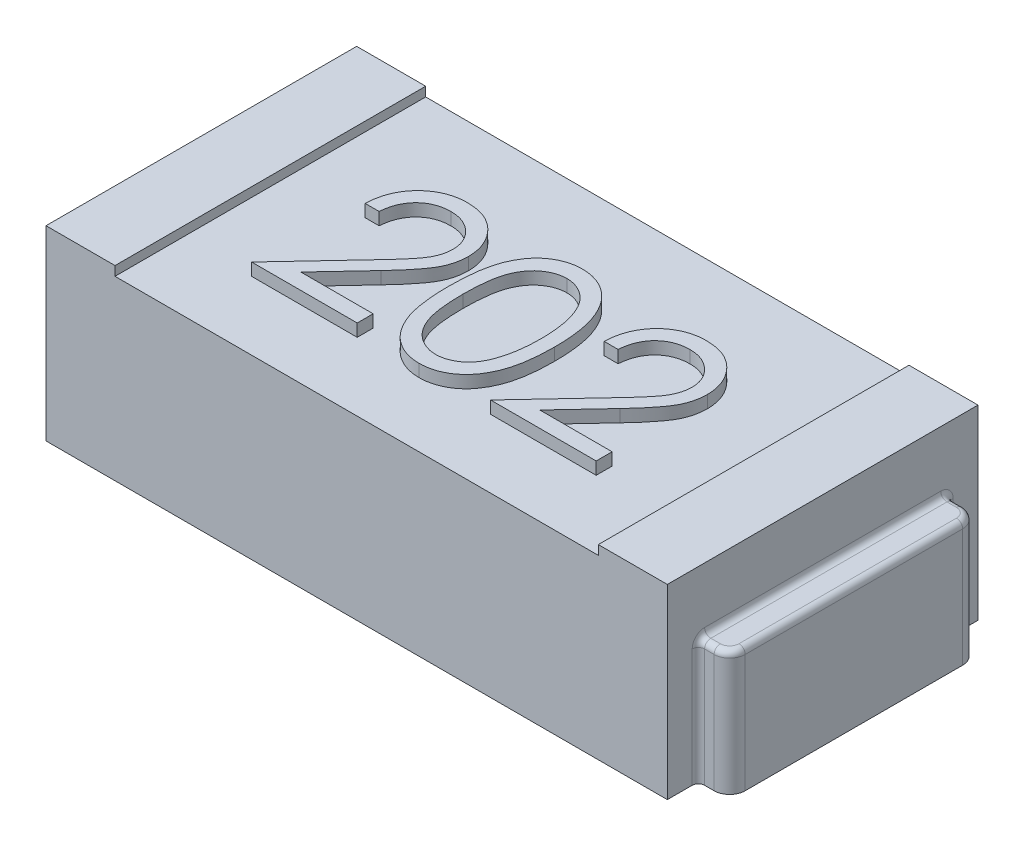
from build123d import *

# Parameters (mm, degrees)
ESQUISSE1_W             = 2
ESQUISSE1_H             = 1
BOSS_EXTRU_1_DEPTH      = 0.6
ESQUISSE2_W             = 1.555645222
ESQUISSE2_H             = 1
ENL_V_MAT_EXTRU_1_DEPTH = 0.03
BOSS_EXTRU_2_DEPTH      = 0.4
CONG_1_R                = 0.02
CONG_1_OF_SYM_TRIE2_R   = 0.02
BOSS_EXTRU_3_DEPTH      = 0.04


with BuildPart() as part:
    # Esquisse1 → Boss.-Extru.1 (new body)
    with BuildSketch(Plane(origin=(0, 0, 0), x_dir=(1, 0, 0), z_dir=(0, 1, 0))):
        Rectangle(ESQUISSE1_W, ESQUISSE1_H)
    extrude(amount=BOSS_EXTRU_1_DEPTH)

    # Esquisse2 → Enlèv. mat.-Extru.1 (cut)
    with BuildSketch(Plane(origin=(0, 0.6, 0), x_dir=(1, 0, 0), z_dir=(0, 1, 0))):
        Rectangle(ESQUISSE2_W, ESQUISSE2_H)
    extrude(amount=-ENL_V_MAT_EXTRU_1_DEPTH, mode=Mode.SUBTRACT)

    # Esquisse3 → Boss.-Extru.2 (add)
    with BuildSketch(Plane(origin=(0, 0, 0), x_dir=(1, 0, 0), z_dir=(0, 1, 0))):
        with BuildLine():
            Line((1, 0.4), (1.050552667, 0.4))
            ThreePointArc((1.050552667, 0.4), (1.085908006, 0.385355339), (1.100552667, 0.35))
            Line((1.100552667, 0.35), (1.100552667, -0.35))
            ThreePointArc((1.100552667, -0.35), (1.085908006, -0.385355339), (1.050552667, -0.4))
            Line((1.050552667, -0.4), (1, -0.4))
            Line((1, -0.4), (1, 0.4))
        make_face()
    boss_extru_2 = extrude(amount=BOSS_EXTRU_2_DEPTH)

    # Congé1
    cong_1_edges = [part.edges().sort_by_distance(p)[0] for p in [
        (1, 0.2, -0.4),
        (1, 0.2, 0.4),
        (1, 0.4, 0),
        (1.025276334, 0.4, 0.4),
        (1.085908006, 0.4, 0.385355339),
        (1.100552667, 0.4, 0),
        (1.085908006, 0.4, -0.385355339),
        (1.025276334, 0.4, -0.4),
    ]]
    fillet(cong_1_edges, radius=CONG_1_R)

    # Symétrie2: Boss.-Extru.2 across plane
    add(boss_extru_2.mirror(Plane(origin=(0, 0, 0), x_dir=(0, 0, 1), z_dir=(1, 0, 0))))

    # Congé1 of Symétrie2
    cong_1_of_sym_trie2_edges = [part.edges().sort_by_distance(p)[0] for p in [
        (-1, 0.2, -0.4),
        (-1, 0.2, 0.4),
        (-1, 0.4, 0),
        (-1.025276334, 0.4, 0.4),
        (-1.085908006, 0.4, 0.385355339),
        (-1.100552667, 0.4, 0),
        (-1.085908006, 0.4, -0.385355339),
        (-1.025276334, 0.4, -0.4),
    ]]
    fillet(cong_1_of_sym_trie2_edges, radius=CONG_1_OF_SYM_TRIE2_R)

    # Esquisse4 → Boss.-Extru.3 (add)
    with BuildSketch(Plane(origin=(0, 0.57, 0), x_dir=(1, 0, 0), z_dir=(0, 1, 0))):
        with BuildLine():
            Line((0.275641026, 0.065854324), (0.230769231, 0.065854324))
            add(Edge.make_bspline(
                [(0.230769231, 0.065854324), (0.231061681, 0.071807307), (0.231636046, 0.08349881), (0.234325802, 0.100545082), (0.238174498, 0.116838625), (0.243616135, 0.132248612), (0.250374174, 0.146911299), (0.258478464, 0.160768444), (0.268077586, 0.173767185), (0.278964262, 0.18578702), (0.290788353, 0.196813816), (0.303546344, 0.206335994), (0.316952777, 0.214381375), (0.330966977, 0.221107267), (0.345747057, 0.226155816), (0.361158894, 0.229901765), (0.377270199, 0.232155528), (0.388247345, 0.232397784), (0.393830128, 0.23252099)],
                knots=[0, 0, 0, 0, 1.7869e-05, 3.5094e-05, 5.1686e-05, 6.8032e-05, 8.4031e-05, 0.000100058, 0.000116104, 0.000132416, 0.000148647, 0.000164532, 0.000180078, 0.00019549, 0.000211074, 0.000226841, 0.000243017, 0.000259759, 0.000259759, 0.000259759, 0.000259759], degree=3))
            add(Edge.make_bspline(
                [(0.393830128, 0.23252099), (0.39931271, 0.232392639), (0.410085788, 0.232140434), (0.425808933, 0.229974573), (0.440777118, 0.226582346), (0.454961085, 0.221823), (0.468247665, 0.215425225), (0.480736672, 0.207739862), (0.492576787, 0.198851315), (0.503234899, 0.188386485), (0.513021768, 0.177214715), (0.521464947, 0.165287872), (0.528695399, 0.152969403), (0.53472221, 0.140165374), (0.539158802, 0.126755227), (0.542527117, 0.112934198), (0.544431033, 0.098559225), (0.544723237, 0.088829717), (0.544871795, 0.08388317)],
                knots=[0, 0, 0, 0, 1.6441e-05, 3.2306e-05, 4.7516e-05, 6.2435e-05, 7.7085e-05, 9.1652e-05, 0.000106376, 0.000121393, 0.000136374, 0.000150882, 0.000165157, 0.000179183, 0.000193247, 0.000207458, 0.000221808, 0.000236648, 0.000236648, 0.000236648, 0.000236648], degree=3))
            add(Edge.make_bspline(
                [(0.544871795, 0.08388317), (0.5446299, 0.076919193), (0.544150356, 0.063113449), (0.540048302, 0.042825611), (0.533641657, 0.023169408), (0.525927749, 0.007349794), (0.518145972, -0.005397848), (0.511133471, -0.015893378), (0.502924212, -0.027194159), (0.493398712, -0.03926235), (0.482754016, -0.052192479), (0.470893707, -0.065976736), (0.45773321, -0.080472703), (0.448496281, -0.090373503), (0.443709936, -0.09550385)],
                knots=[0, 0, 0, 0, 2.0874e-05, 4.1382e-05, 6.1843e-05, 8.2763e-05, 9.3997e-05, 0.000106637, 0.000120621, 0.000135888, 0.000152753, 0.000170863, 0.000190435, 0.000211484, 0.000211484, 0.000211484, 0.000211484], degree=3))
            Line((0.443709936, -0.09550385), (0.318609776, -0.229017471))
            Line((0.318609776, -0.229017471), (0.551282051, -0.229017471))
            Line((0.551282051, -0.229017471), (0.551282051, -0.280299523))
            Line((0.551282051, -0.280299523), (0.211538462, -0.280299523))
            Line((0.211538462, -0.280299523), (0.405448718, -0.073368433))
            add(Edge.make_bspline(
                [(0.405448718, -0.073368433), (0.410169845, -0.068440103), (0.419238163, -0.058973791), (0.432064245, -0.045153368), (0.443584101, -0.032332005), (0.4538723, -0.020533927), (0.462705658, -0.00958656), (0.470544548, 0.000155541), (0.476825347, 0.009120462), (0.483641832, 0.019511978), (0.490243829, 0.032199452), (0.495917023, 0.047704265), (0.499376287, 0.063665301), (0.499791263, 0.074451306), (0.5, 0.079876759)],
                knots=[0, 0, 0, 0, 2.0474e-05, 3.9327e-05, 5.6561e-05, 7.2184e-05, 8.6278e-05, 9.8762e-05, 0.000109683, 0.000119101, 0.000136035, 0.000152448, 0.000168517, 0.00018478, 0.00018478, 0.00018478, 0.00018478], degree=3))
            add(Edge.make_bspline(
                [(0.5, 0.079876759), (0.49990918, 0.083288388), (0.49973019, 0.090012052), (0.498150519, 0.099870018), (0.495763304, 0.109379277), (0.492342553, 0.11856908), (0.487827304, 0.12734703), (0.482331107, 0.135723813), (0.47598967, 0.143822236), (0.468653774, 0.151415565), (0.460594985, 0.158370023), (0.452081521, 0.164530606), (0.443074363, 0.169679051), (0.433611489, 0.17389955), (0.423719279, 0.177210319), (0.413378601, 0.179504402), (0.402618027, 0.180944757), (0.395270385, 0.181139638), (0.391526442, 0.181238939)],
                knots=[0, 0, 0, 0, 1.0229e-05, 2.0159e-05, 2.9876e-05, 3.9606e-05, 4.9505e-05, 5.9423e-05, 6.9622e-05, 8.0319e-05, 9.1042e-05, 0.000101521, 0.000111795, 0.000122107, 0.000132559, 0.000143032, 0.000153841, 0.00016507, 0.00016507, 0.00016507, 0.00016507], degree=3))
            add(Edge.make_bspline(
                [(0.391526442, 0.181238939), (0.387616323, 0.181136791), (0.379937495, 0.180936191), (0.368663348, 0.179532953), (0.357908237, 0.177112119), (0.347645108, 0.173801165), (0.337856595, 0.169592801), (0.328590303, 0.164351123), (0.319867034, 0.158096338), (0.311670387, 0.15100483), (0.30411839, 0.143109459), (0.297483122, 0.134308036), (0.291685406, 0.124761262), (0.286626944, 0.114494898), (0.282518988, 0.103415786), (0.279379967, 0.091563257), (0.276896132, 0.078988774), (0.276066343, 0.07030519), (0.275641026, 0.065854324)],
                knots=[0, 0, 0, 0, 1.1729e-05, 2.3035e-05, 3.4018e-05, 4.4756e-05, 5.5343e-05, 6.5928e-05, 7.6628e-05, 8.7492e-05, 9.8403e-05, 0.00010934, 0.000120489, 0.000131867, 0.000143625, 0.00015587, 0.000168619, 0.000182025, 0.000182025, 0.000182025, 0.000182025], degree=3))
        make_face()
        with BuildLine():
            add(Edge.make_bspline(
                [(-0.173076923, -0.030499843), (-0.173030063, -0.022485931), (-0.172939038, -0.00691879), (-0.171926406, 0.01576473), (-0.170244214, 0.037044772), (-0.167938875, 0.056922352), (-0.16513345, 0.075402605), (-0.16138838, 0.092436141), (-0.157129408, 0.108101799), (-0.152193345, 0.122450663), (-0.14662366, 0.13567605), (-0.140561623, 0.148022507), (-0.133766653, 0.159471354), (-0.126627094, 0.170205324), (-0.11885394, 0.180048709), (-0.110668399, 0.189140518), (-0.101750988, 0.197270626), (-0.092404844, 0.20467724), (-0.082545349, 0.211170022), (-0.07245354, 0.216888984), (-0.062059953, 0.22177468), (-0.051336213, 0.225616171), (-0.040378704, 0.228789149), (-0.029149123, 0.230958998), (-0.017628929, 0.232324271), (-0.009853009, 0.232454795), (-0.005909455, 0.23252099)],
                knots=[0, 0, 0, 0, 2.404e-05, 4.6699e-05, 6.8101e-05, 8.8066e-05, 0.000106723, 0.000124149, 0.000140356, 0.000155402, 0.000169633, 0.000183384, 0.000196628, 0.000209546, 0.000222029, 0.000234224, 0.000246203, 0.000258186, 0.000269964, 0.00028158, 0.000292962, 0.000304369, 0.000315719, 0.000327152, 0.000338644, 0.00035047, 0.00035047, 0.00035047, 0.00035047], degree=3))
            add(Edge.make_bspline(
                [(-0.005909455, 0.23252099), (-0.001932958, 0.232451302), (0.005975043, 0.232312715), (0.017666525, 0.230980723), (0.029087908, 0.228770563), (0.0401905, 0.225638995), (0.051065498, 0.221753898), (0.061627842, 0.21688431), (0.071943139, 0.211215901), (0.081847466, 0.204555347), (0.091449554, 0.197129307), (0.100513548, 0.18873464), (0.109040275, 0.179456109), (0.117136747, 0.169392986), (0.124573261, 0.158352259), (0.13165518, 0.146525958), (0.137994042, 0.133707263), (0.144098996, 0.120110053), (0.149368565, 0.105358102), (0.154120886, 0.089534565), (0.157960739, 0.072452538), (0.161159206, 0.054201646), (0.163637048, 0.034714862), (0.165441712, 0.01403396), (0.16639501, -0.007854667), (0.166574538, -0.022820074), (0.166666667, -0.030499843)],
                knots=[0, 0, 0, 0, 1.1926e-05, 2.3717e-05, 3.5247e-05, 4.6791e-05, 5.8292e-05, 6.9855e-05, 8.1646e-05, 9.3563e-05, 0.000105625, 0.000118029, 0.000130574, 0.000143401, 0.000156736, 0.000170478, 0.000184722, 0.000199611, 0.000215168, 0.000231679, 0.000249148, 0.000267657, 0.000287249, 0.00030806, 0.000329918, 0.000352958, 0.000352958, 0.000352958, 0.000352958], degree=3))
            add(Edge.make_bspline(
                [(0.166666667, -0.030499843), (0.166573583, -0.038146116), (0.166392214, -0.053044566), (0.165452398, -0.074834705), (0.163601165, -0.095405854), (0.161285453, -0.114807349), (0.158078172, -0.132958437), (0.154134577, -0.14992193), (0.14975596, -0.165771083), (0.144350989, -0.180376056), (0.138435173, -0.193940588), (0.131998717, -0.206607324), (0.125103027, -0.218488222), (0.117590349, -0.229488186), (0.109582719, -0.239685137), (0.100908749, -0.248899083), (0.091812951, -0.257352037), (0.082182606, -0.264873698), (0.072123813, -0.271457241), (0.061843945, -0.277344934), (0.051160605, -0.282092462), (0.040315897, -0.286168896), (0.029154702, -0.289283247), (0.017690932, -0.291436655), (0.005982898, -0.292946919), (-0.001931611, -0.29306213), (-0.005909455, -0.293120035)],
                knots=[0, 0, 0, 0, 2.294e-05, 4.4698e-05, 6.541e-05, 8.4889e-05, 0.0001033, 0.000120672, 0.000137126, 0.000152589, 0.000167346, 0.000181501, 0.000195192, 0.000208527, 0.000221432, 0.000234046, 0.00024645, 0.000258652, 0.000270653, 0.000282492, 0.000294147, 0.000305682, 0.000317226, 0.000328855, 0.000340657, 0.000352583, 0.000352583, 0.000352583, 0.000352583], degree=3))
            add(Edge.make_bspline(
                [(-0.005909455, -0.293120035), (-0.0098529, -0.293053413), (-0.017628604, -0.292922047), (-0.029150379, -0.291562943), (-0.040333585, -0.289377871), (-0.051233407, -0.286318356), (-0.061905766, -0.282573379), (-0.072205236, -0.277694282), (-0.082246333, -0.272075129), (-0.09200227, -0.265675783), (-0.101289721, -0.258344114), (-0.110160951, -0.25023493), (-0.118393096, -0.241145871), (-0.12605511, -0.231220454), (-0.133337123, -0.22054999), (-0.140035605, -0.208988794), (-0.146231441, -0.196582707), (-0.151894797, -0.183251577), (-0.156916034, -0.168800873), (-0.161351421, -0.153065276), (-0.164853444, -0.135905899), (-0.167851009, -0.117460561), (-0.170268778, -0.09765), (-0.171919396, -0.07646346), (-0.172939583, -0.053914145), (-0.173030308, -0.038447034), (-0.173076923, -0.030499843)],
                knots=[0, 0, 0, 0, 1.1826e-05, 2.3318e-05, 3.475e-05, 4.5977e-05, 5.7256e-05, 6.8638e-05, 8.0117e-05, 9.1757e-05, 0.000103599, 0.000115578, 0.000127773, 0.000140335, 0.00015317, 0.0001665, 0.000180386, 0.000194748, 0.000209921, 0.000226252, 0.000243755, 0.000262428, 0.000282305, 0.000303608, 0.000326166, 0.000350006, 0.000350006, 0.000350006, 0.000350006], degree=3))
        make_face()
        with BuildLine():
            add(Edge.make_bspline(
                [(-0.128205128, -0.030299523), (-0.128188064, -0.036977908), (-0.128154947, -0.049939343), (-0.127289775, -0.068774095), (-0.126111171, -0.086341285), (-0.124590985, -0.102663218), (-0.122333421, -0.117684649), (-0.11980388, -0.131508889), (-0.116725582, -0.14406278), (-0.113083436, -0.155432467), (-0.108934994, -0.165810906), (-0.104405585, -0.175468222), (-0.099539767, -0.184518499), (-0.094094174, -0.192880443), (-0.088163451, -0.200581323), (-0.081881557, -0.207757442), (-0.075014045, -0.214157011), (-0.06551351, -0.221832276), (-0.052971157, -0.229763581), (-0.037168234, -0.236670165), (-0.020929884, -0.241010516), (-0.009908277, -0.241562481), (-0.004407051, -0.241837984)],
                knots=[0, 0, 0, 0, 2.0033e-05, 3.888e-05, 5.6549e-05, 7.2854e-05, 8.8039e-05, 0.000102104, 0.000115004, 0.000126787, 0.000137891, 0.00014851, 0.000158774, 0.000168692, 0.000178408, 0.000187915, 0.000197268, 0.000206529, 0.000224535, 0.00024158, 0.000258123, 0.000274609, 0.000274609, 0.000274609, 0.000274609], degree=3))
            add(Edge.make_bspline(
                [(-0.004407051, -0.241837984), (0.001129759, -0.24160973), (0.012191948, -0.241153692), (0.028353919, -0.236753873), (0.044043957, -0.230115367), (0.056339949, -0.222265723), (0.065694598, -0.214790248), (0.072397025, -0.208416726), (0.078548746, -0.201280174), (0.084383328, -0.193580275), (0.089734625, -0.18516992), (0.094600787, -0.176089552), (0.099041266, -0.166313955), (0.101571129, -0.159489707), (0.102864583, -0.156000644)],
                knots=[0, 0, 0, 0, 1.6578e-05, 3.3121e-05, 4.9903e-05, 6.7548e-05, 7.6668e-05, 8.5806e-05, 9.5248e-05, 0.000104903, 0.000114767, 0.000125119, 0.000135787, 0.000146948, 0.000146948, 0.000146948, 0.000146948], degree=3))
            add(Edge.make_bspline(
                [(0.102864583, -0.156000644), (0.104371979, -0.151539253), (0.107432638, -0.142480715), (0.111377177, -0.128428765), (0.114483663, -0.113685513), (0.117278429, -0.098339068), (0.119186009, -0.082276253), (0.12072141, -0.06554677), (0.121625794, -0.048138004), (0.121737902, -0.036310148), (0.121794872, -0.030299523)],
                knots=[0, 0, 0, 0, 1.4127e-05, 2.8683e-05, 4.3751e-05, 5.9313e-05, 7.5463e-05, 9.2257e-05, 0.000109708, 0.00012774, 0.00012774, 0.00012774, 0.00012774], degree=3))
            add(Edge.make_bspline(
                [(0.121794872, -0.030299523), (0.121716273, -0.024289869), (0.121562518, -0.012533703), (0.120974805, 0.00468318), (0.119457152, 0.021035717), (0.117771564, 0.036594356), (0.115286246, 0.051272971), (0.11260656, 0.065194443), (0.109006386, 0.078186304), (0.105160704, 0.090451958), (0.100759219, 0.101852052), (0.095914114, 0.112439736), (0.090739577, 0.122266125), (0.085119257, 0.131304259), (0.079119874, 0.139594623), (0.072583081, 0.146970993), (0.065768171, 0.153661989), (0.056222858, 0.161299499), (0.043726531, 0.169086884), (0.028177153, 0.176253421), (0.011995633, 0.180368891), (0.001056568, 0.180949132), (-0.004407051, 0.181238939)],
                knots=[0, 0, 0, 0, 1.8031e-05, 3.5273e-05, 5.1659e-05, 6.7289e-05, 8.2207e-05, 9.6311e-05, 0.000109795, 0.000122624, 0.000134863, 0.000146427, 0.000157539, 0.000168156, 0.000178333, 0.000188198, 0.000197689, 0.00020695, 0.000224818, 0.00024172, 0.000258142, 0.000274528, 0.000274528, 0.000274528, 0.000274528], degree=3))
            add(Edge.make_bspline(
                [(-0.004407051, 0.181238939), (-0.009937136, 0.180948732), (-0.02100738, 0.18036779), (-0.037357087, 0.176268754), (-0.053029138, 0.169124045), (-0.06549242, 0.161273706), (-0.075044389, 0.153796804), (-0.081770488, 0.147313025), (-0.088077084, 0.140220703), (-0.093886756, 0.132449001), (-0.099328082, 0.124096805), (-0.104325369, 0.11509841), (-0.108827845, 0.105408216), (-0.112982779, 0.095034439), (-0.116636034, 0.083665733), (-0.119649458, 0.071127305), (-0.122433322, 0.057347035), (-0.124404075, 0.042244248), (-0.12615604, 0.025918226), (-0.127281947, 0.008307181), (-0.128157841, -0.01055916), (-0.12818905, -0.023587611), (-0.128205128, -0.030299523)],
                knots=[0, 0, 0, 0, 1.6586e-05, 3.3202e-05, 5.0195e-05, 6.8064e-05, 7.7262e-05, 8.6542e-05, 9.6049e-05, 0.000105705, 0.000115623, 0.000125935, 0.000136554, 0.000147658, 0.000159441, 0.000172341, 0.000186327, 0.000201596, 0.000218011, 0.00023558, 0.000254527, 0.000274661, 0.000274661, 0.000274661, 0.000274661], degree=3))
        make_face(mode=Mode.SUBTRACT)
        with BuildLine():
            Line((-0.493589744, 0.065854324), (-0.538461538, 0.065854324))
            add(Edge.make_bspline(
                [(-0.538461538, 0.065854324), (-0.538169088, 0.071807307), (-0.537594723, 0.08349881), (-0.534904968, 0.100545082), (-0.531056271, 0.116838625), (-0.525614635, 0.132248612), (-0.518856595, 0.146911299), (-0.510752305, 0.160768444), (-0.501153184, 0.173767185), (-0.490266507, 0.18578702), (-0.478442416, 0.196813816), (-0.465684425, 0.206335994), (-0.452277992, 0.214381375), (-0.438263792, 0.221107267), (-0.423483712, 0.226155816), (-0.408071875, 0.229901765), (-0.39196057, 0.232155528), (-0.380983424, 0.232397784), (-0.375400641, 0.23252099)],
                knots=[0, 0, 0, 0, 1.7869e-05, 3.5094e-05, 5.1686e-05, 6.8032e-05, 8.4031e-05, 0.000100058, 0.000116104, 0.000132416, 0.000148647, 0.000164532, 0.000180078, 0.00019549, 0.000211074, 0.000226841, 0.000243017, 0.000259759, 0.000259759, 0.000259759, 0.000259759], degree=3))
            add(Edge.make_bspline(
                [(-0.375400641, 0.23252099), (-0.369918059, 0.232392639), (-0.359144981, 0.232140434), (-0.343421836, 0.229974573), (-0.328453651, 0.226582346), (-0.314269685, 0.221823), (-0.300983104, 0.215425225), (-0.288494098, 0.207739862), (-0.276653982, 0.198851315), (-0.26599587, 0.188386485), (-0.256209001, 0.177214715), (-0.247765822, 0.165287872), (-0.24053537, 0.152969403), (-0.234508559, 0.140165374), (-0.230071968, 0.126755227), (-0.226703652, 0.112934198), (-0.224799736, 0.098559225), (-0.224507533, 0.088829717), (-0.224358974, 0.08388317)],
                knots=[0, 0, 0, 0, 1.6441e-05, 3.2306e-05, 4.7516e-05, 6.2435e-05, 7.7085e-05, 9.1652e-05, 0.000106376, 0.000121393, 0.000136374, 0.000150882, 0.000165157, 0.000179183, 0.000193247, 0.000207458, 0.000221808, 0.000236648, 0.000236648, 0.000236648, 0.000236648], degree=3))
            add(Edge.make_bspline(
                [(-0.224358974, 0.08388317), (-0.224600869, 0.076919193), (-0.225080414, 0.063113449), (-0.229182467, 0.042825611), (-0.235589112, 0.023169408), (-0.24330302, 0.007349794), (-0.251084798, -0.005397848), (-0.258097299, -0.015893378), (-0.266306557, -0.027194159), (-0.275832057, -0.03926235), (-0.286476753, -0.052192479), (-0.298337062, -0.065976736), (-0.31149756, -0.080472703), (-0.320734488, -0.090373503), (-0.325520833, -0.09550385)],
                knots=[0, 0, 0, 0, 2.0874e-05, 4.1382e-05, 6.1843e-05, 8.2763e-05, 9.3997e-05, 0.000106637, 0.000120621, 0.000135888, 0.000152753, 0.000170863, 0.000190435, 0.000211484, 0.000211484, 0.000211484, 0.000211484], degree=3))
            Line((-0.325520833, -0.09550385), (-0.450620994, -0.229017471))
            Line((-0.450620994, -0.229017471), (-0.217948718, -0.229017471))
            Line((-0.217948718, -0.229017471), (-0.217948718, -0.280299523))
            Line((-0.217948718, -0.280299523), (-0.557692308, -0.280299523))
            Line((-0.557692308, -0.280299523), (-0.363782051, -0.073368433))
            add(Edge.make_bspline(
                [(-0.363782051, -0.073368433), (-0.359060925, -0.068440103), (-0.349992606, -0.058973791), (-0.337166524, -0.045153368), (-0.325646669, -0.032332005), (-0.31535847, -0.020533927), (-0.306525112, -0.00958656), (-0.298686221, 0.000155541), (-0.292405423, 0.009120462), (-0.285588938, 0.019511978), (-0.27898694, 0.032199452), (-0.273313747, 0.047704265), (-0.269854482, 0.063665301), (-0.269439506, 0.074451306), (-0.269230769, 0.079876759)],
                knots=[0, 0, 0, 0, 2.0474e-05, 3.9327e-05, 5.6561e-05, 7.2184e-05, 8.6278e-05, 9.8762e-05, 0.000109683, 0.000119101, 0.000136035, 0.000152448, 0.000168517, 0.00018478, 0.00018478, 0.00018478, 0.00018478], degree=3))
            add(Edge.make_bspline(
                [(-0.269230769, 0.079876759), (-0.26932159, 0.083288388), (-0.269500579, 0.090012052), (-0.27108025, 0.099870018), (-0.273467465, 0.109379277), (-0.276888216, 0.11856908), (-0.281403465, 0.12734703), (-0.286899662, 0.135723813), (-0.2932411, 0.143822236), (-0.300576995, 0.151415565), (-0.308635784, 0.158370023), (-0.317149248, 0.164530606), (-0.326156406, 0.169679051), (-0.33561928, 0.17389955), (-0.34551149, 0.177210319), (-0.355852168, 0.179504402), (-0.366612742, 0.180944757), (-0.373960384, 0.181139638), (-0.377704327, 0.181238939)],
                knots=[0, 0, 0, 0, 1.0229e-05, 2.0159e-05, 2.9876e-05, 3.9606e-05, 4.9505e-05, 5.9423e-05, 6.9622e-05, 8.0319e-05, 9.1042e-05, 0.000101521, 0.000111795, 0.000122107, 0.000132559, 0.000143032, 0.000153841, 0.00016507, 0.00016507, 0.00016507, 0.00016507], degree=3))
            add(Edge.make_bspline(
                [(-0.377704327, 0.181238939), (-0.381614446, 0.181136791), (-0.389293274, 0.180936191), (-0.400567421, 0.179532953), (-0.411322533, 0.177112119), (-0.421585662, 0.173801165), (-0.431374174, 0.169592801), (-0.440640466, 0.164351123), (-0.449363736, 0.158096338), (-0.457560382, 0.15100483), (-0.465112379, 0.143109459), (-0.471747647, 0.134308036), (-0.477545363, 0.124761262), (-0.482603825, 0.114494898), (-0.486711781, 0.103415786), (-0.489850802, 0.091563257), (-0.492334638, 0.078988774), (-0.493164426, 0.07030519), (-0.493589744, 0.065854324)],
                knots=[0, 0, 0, 0, 1.1729e-05, 2.3035e-05, 3.4018e-05, 4.4756e-05, 5.5343e-05, 6.5928e-05, 7.6628e-05, 8.7492e-05, 9.8403e-05, 0.00010934, 0.000120489, 0.000131867, 0.000143625, 0.00015587, 0.000168619, 0.000182025, 0.000182025, 0.000182025, 0.000182025], degree=3))
        make_face()
    extrude(amount=BOSS_EXTRU_3_DEPTH)


solid = part.part
